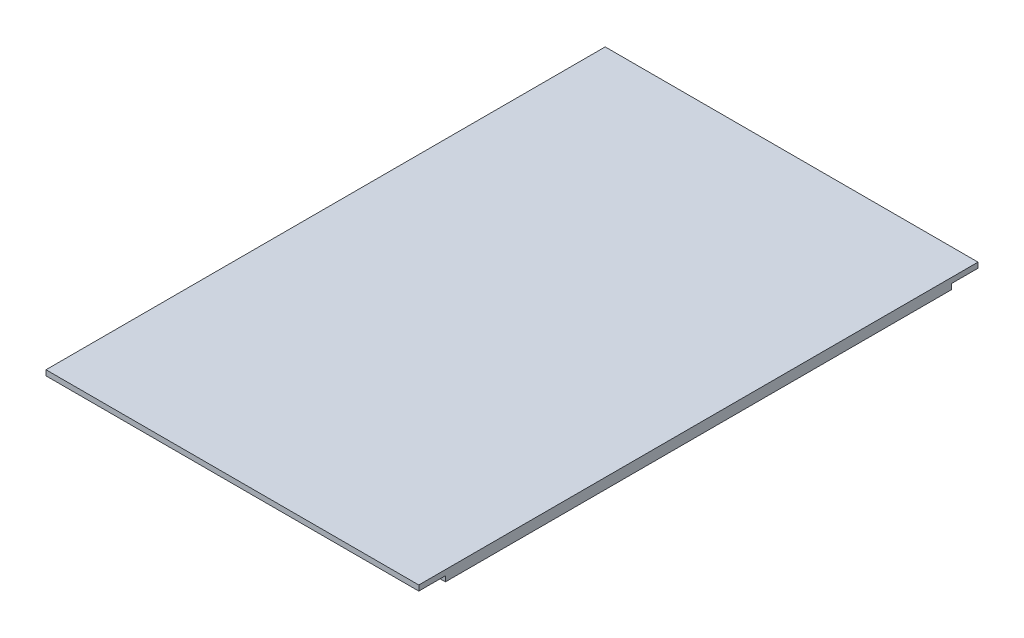
from build123d import *

# Parameters (mm, degrees)
SKETCH2_W               = 140
SKETCH2_H               = 420
BOSS_EXTRUDE1_DEPTH     = 4
BOSS_EXTRUDE2_DEPTH     = 25
SKETCH4_W               = 10.25
SKETCH4_H               = 80.25
CUT_EXTRUDE1_DEPTH      = 25.4
SKETCH7_W               = 130
SKETCH7_H               = 10
CUT_EXTRUDE2_DEPTH      = 2.45
SKETCH9_W               = 140
SKETCH9_H               = 115
SKETCH9_W_2             = 10.25
SKETCH9_H_2             = 80.25
CUT_EXTRUDE3_DEPTH      = 1
CUT_EXTRUDE3_DEPTH_BACK = 30
SKETCH10_W              = 140
SKETCH10_H              = 10
BOSS_EXTRUDE3_DEPTH     = 2


with BuildPart() as part:
    # Sketch2 → Boss-Extrude1 (new body)
    with BuildSketch(Plane(origin=(0, 0, 0), x_dir=(1, 0, 0), z_dir=(0, 1, 0))):
        Rectangle(SKETCH2_W, SKETCH2_H)
    extrude(amount=BOSS_EXTRUDE1_DEPTH)

    # Sketch3 → Boss-Extrude2 (add)
    with BuildSketch(Plane(origin=(0, 4, 0), x_dir=(1, 0, 0), z_dir=(0, 1, 0))):
        with BuildLine():
            Line((-37.5, -165), (-37.5, -145))
            Line((-37.5, -145), (-43.5, -145))
            Line((-43.5, -145), (-43.5, -165))
            ThreePointArc((-43.5, -165), (0, -208.5), (43.5, -165))
            Line((43.5, -165), (43.5, -145))
            Line((43.5, -145), (37.5, -145))
            Line((37.5, -145), (37.5, -165))
            ThreePointArc((37.5, -165), (0, -202.5), (-37.5, -165))
        make_face()
    extrude(amount=BOSS_EXTRUDE2_DEPTH)

    # Sketch4 → Cut-Extrude1 (cut)
    with BuildSketch(Plane(origin=(0, 4, 0), x_dir=(1, 0, 0), z_dir=(0, 1, 0))):
        with Locations((-59.875, 139.875)):
            Rectangle(SKETCH4_W, SKETCH4_H)
        with Locations((59.875, 139.875)):
            Rectangle(SKETCH4_W, SKETCH4_H)
    extrude(amount=-CUT_EXTRUDE1_DEPTH, mode=Mode.SUBTRACT)

    # Sketch7 → Cut-Extrude2 (cut)
    with BuildSketch(Plane(origin=(0, 4, 0), x_dir=(1, 0, 0), z_dir=(0, 1, 0))):
        with Locations((0, 200)):
            Rectangle(SKETCH7_W, SKETCH7_H)
    extrude(amount=-CUT_EXTRUDE2_DEPTH, mode=Mode.SUBTRACT)

    # Sketch9 → Cut-Extrude3 (cut, two sides)
    with BuildSketch(Plane.XZ) as cut_extrude3_sk:
        with Locations((0, 152.5)):
            Rectangle(SKETCH9_W, SKETCH9_H)
        with Locations((0, -152.5)):
            Rectangle(SKETCH9_W, SKETCH9_H)
        with Locations((-59.875, -139.875)):
            Rectangle(SKETCH9_W_2, SKETCH9_H_2, mode=Mode.SUBTRACT)
        with Locations((59.875, -139.875)):
            Rectangle(SKETCH9_W_2, SKETCH9_H_2, mode=Mode.SUBTRACT)
    extrude(amount=CUT_EXTRUDE3_DEPTH, mode=Mode.SUBTRACT)
    extrude(cut_extrude3_sk.sketch, amount=-CUT_EXTRUDE3_DEPTH_BACK, mode=Mode.SUBTRACT)

    # Sketch10 → Boss-Extrude3 (add)
    with BuildSketch(Plane(origin=(0, 4, 0), x_dir=(1, 0, 0), z_dir=(0, 1, 0))):
        with Locations((0, 100)):
            Rectangle(SKETCH10_W, SKETCH10_H)
        with Locations((0, -100)):
            Rectangle(SKETCH10_W, SKETCH10_H)
    extrude(amount=-BOSS_EXTRUDE3_DEPTH)


solid = part.part
